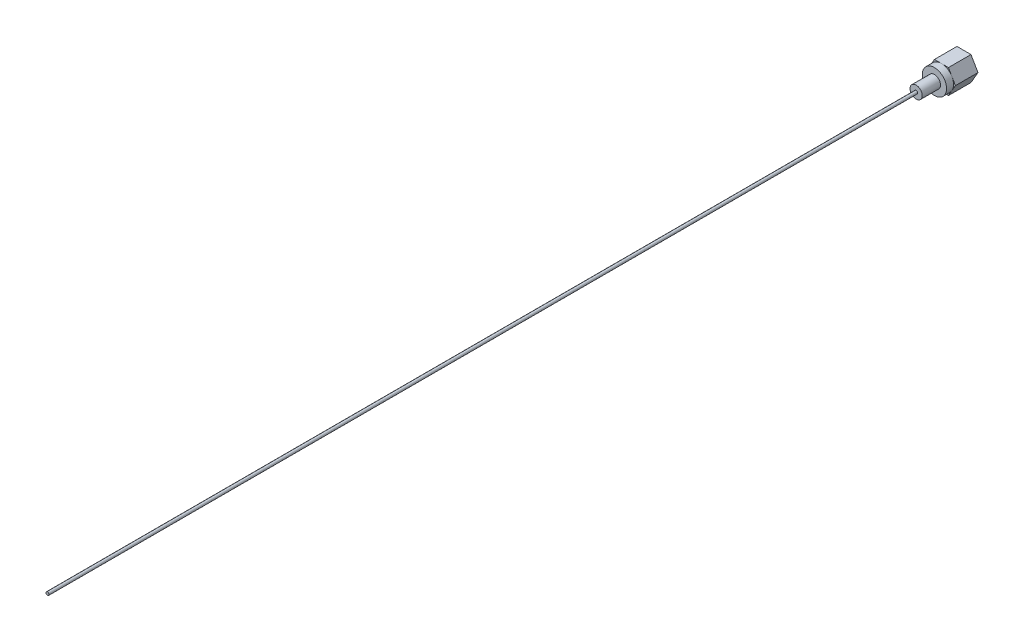
from build123d import *

# Parameters (mm, degrees)
BOSS_EXTRUDE1_DEPTH = 7.4
SKETCH2_R           = 3.983716857
BOSS_EXTRUDE2_DEPTH = 2.3
SKETCH3_R           = 2
BOSS_EXTRUDE3_DEPTH = 6
SKETCH4_R           = 0.5
BOSS_EXTRUDE4_DEPTH = 285


with BuildPart() as part:
    # Sketch1 → Boss-Extrude1 (new body)
    with BuildSketch(Plane.XY):
        Polygon((2.3, -3.983716857), (4.6, 0), (2.3, 3.983716857), (-2.3, 3.983716857), (-4.6, 0), (-2.3, -3.983716857), align=None)
    extrude(amount=BOSS_EXTRUDE1_DEPTH)

    # Sketch2 → Boss-Extrude2 (add)
    with BuildSketch(Plane.XY.offset(7.4)):
        Circle(SKETCH2_R)
    extrude(amount=BOSS_EXTRUDE2_DEPTH)

    # Sketch3 → Boss-Extrude3 (add)
    with BuildSketch(Plane.XY.offset(9.7)):
        Circle(SKETCH3_R)
    extrude(amount=BOSS_EXTRUDE3_DEPTH)

    # Sketch4 → Boss-Extrude4 (add)
    with BuildSketch(Plane.XY.offset(15.7)):
        Circle(SKETCH4_R)
    extrude(amount=BOSS_EXTRUDE4_DEPTH)


solid = part.part
